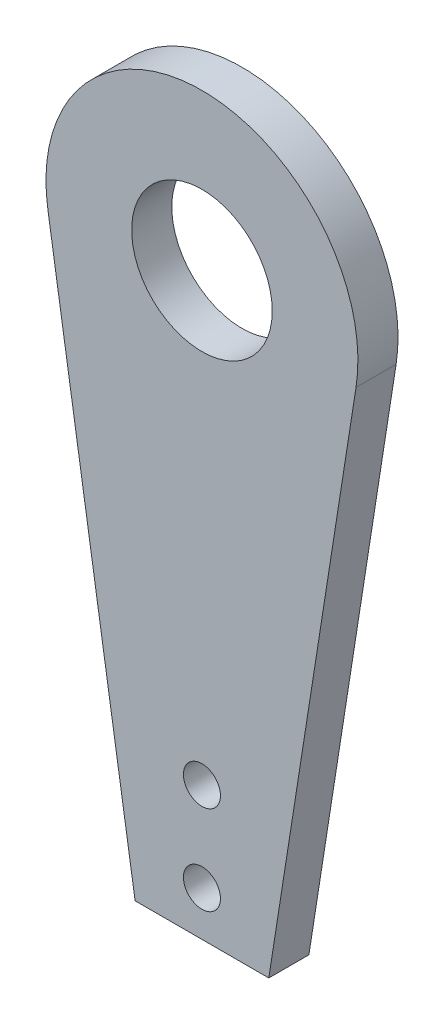
from build123d import *

# Parameters (mm, degrees)
SKETCH1_R           = 2.075
SKETCH1_R_2         = 7.8875
BOSS_EXTRUDE2_DEPTH = 4.5


with BuildPart() as part:
    # Sketch1 → Boss-Extrude2 (new body)
    with BuildSketch(Plane.XY):
        with BuildLine():
            Line((-7.5, -5), (7.5, -5))
            Line((7.5, -5), (17.287829772, 57.283211128))
            ThreePointArc((17.287829772, 57.283211128), (0, 77.5), (-17.287829772, 57.283211128))
            Line((-17.287829772, 57.283211128), (-7.5, -5))
        make_face()
        Circle(SKETCH1_R, mode=Mode.SUBTRACT)
        with Locations((0, 60)):
            Circle(SKETCH1_R_2, mode=Mode.SUBTRACT)
        with Locations((0, 10)):
            Circle(SKETCH1_R, mode=Mode.SUBTRACT)
    extrude(amount=BOSS_EXTRUDE2_DEPTH)


solid = part.part
